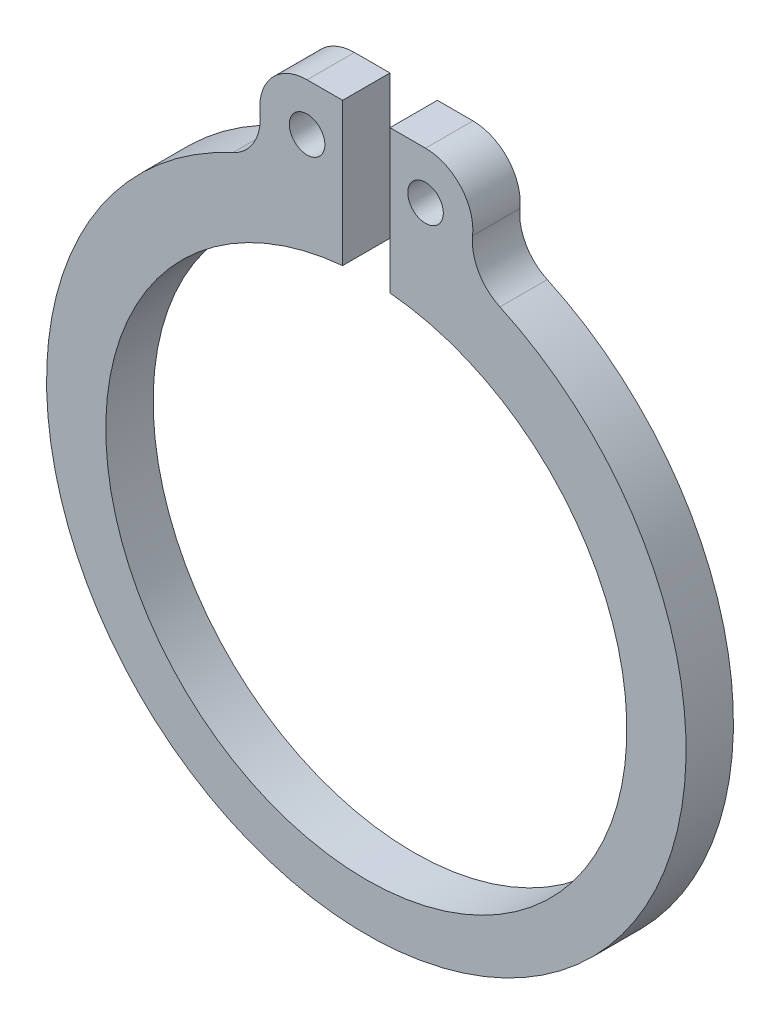
from build123d import *

# Parameters (mm, degrees)
IZIM1_R                     = 0.75
Y_KSEKLIK_EKSTR_ZYON1_DEPTH = 1


with BuildPart() as part:
    # Çizim1 → Yükseklik-Ekstrüzyon1 (new body, symmetric)
    with BuildSketch(Plane.XY):
        with BuildLine():
            Line((-2.5, 16.498872216), (-1, 16.498872216))
            Line((-1, 16.498872216), (-1, 10.45445115))
            ThreePointArc((-1, 10.45445115), (0, -11.5), (1, 10.45445115))
            Line((1, 10.45445115), (1, 16.498872216))
            Line((1, 16.498872216), (2.5, 16.498872216))
            ThreePointArc((2.5, 16.498872216), (3.985473902, 15.837481746), (4.487915198, 14.290994496))
            ThreePointArc((4.487915198, 14.290994496), (4.738807919, 13.092499976), (5.641216256, 12.264855448))
            ThreePointArc((5.641216256, 12.264855448), (0, -13.5), (-5.641216256, 12.264855448))
            ThreePointArc((-5.641216256, 12.264855448), (-4.738807919, 13.092499976), (-4.487915198, 14.290994496))
            ThreePointArc((-4.487915198, 14.290994496), (-3.985473902, 15.837481746), (-2.5, 16.498872216))
        make_face()
        with Locations((-2.5, 14.5)):
            Circle(IZIM1_R, mode=Mode.SUBTRACT)
        with Locations((2.5, 14.5)):
            Circle(IZIM1_R, mode=Mode.SUBTRACT)
    extrude(amount=Y_KSEKLIK_EKSTR_ZYON1_DEPTH, both=True)


solid = part.part
